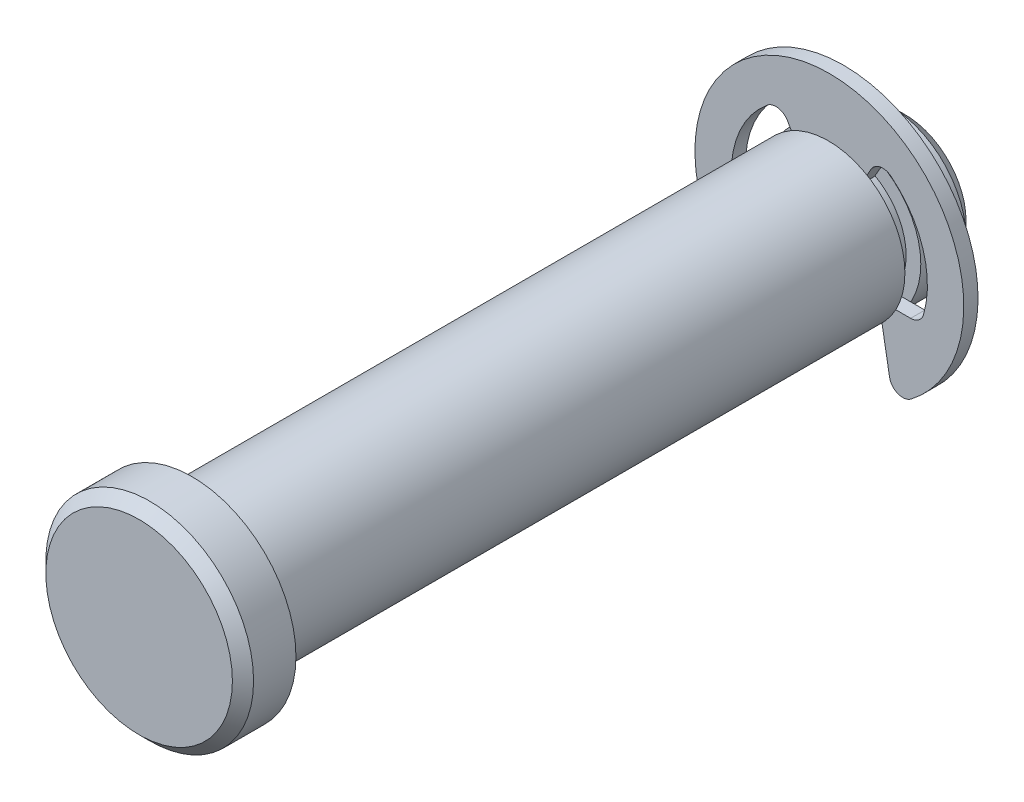
from build123d import *

# Parameters (mm, degrees)
SKETCH2_R      = 4.7625
EXTRUDE1_DEPTH = 22.225
SKETCH3_W      = 0.9906
SKETCH3_H      = 0.9144
SKETCH8_R      = 6.477
EXTRUDE6_DEPTH = 3.302
CHAMFER2_SIZE  = 0.6604
SKETCH4_R      = 8.382
SKETCH4_R_2    = 3.8481
EXTRUDE2_DEPTH = 0.4445
EXTRUDE4_DEPTH = 23.225
EXTRUDE5_DEPTH = 0.889
FILLET1_R      = 0.8382
CHAMFER1_SIZE  = 0.9525


with BuildPart() as part:
    # Sketch2 → Extrude1 (new body, symmetric)
    with BuildSketch(Plane.XY):
        Circle(SKETCH2_R)
    extrude(amount=EXTRUDE1_DEPTH, both=True)

    # Sketch3 → Cut-Revolve1 (revolve, cut)
    with BuildSketch(Plane(origin=(0, 0, 0), x_dir=(0, 0, -1), z_dir=(1, 0, 0))):
        with Locations((17.9578, 4.3053)):
            Rectangle(SKETCH3_W, SKETCH3_H)
    revolve(axis=Axis((0, 0, 22.225), (0, 0, -1)), mode=Mode.SUBTRACT)

    # Sketch8 → Extrude6 (add)
    with BuildSketch(Plane.XY.offset(22.225)):
        Circle(SKETCH8_R)
    extrude(amount=EXTRUDE6_DEPTH)

    # Chamfer2
    chamfer2_edges = [part.edges().sort_by_distance(p)[0] for p in [
        (-6.477, 0, 25.527),
    ]]
    chamfer(chamfer2_edges, length=CHAMFER2_SIZE)

    # Chamfer1
    chamfer1_edges = [part.edges().sort_by_distance(p)[0] for p in [
        (-4.7625, 0, -22.225),
    ]]
    chamfer(chamfer1_edges, length=CHAMFER1_SIZE)


with BuildPart() as body_2:
    # Sketch4 → Extrude2 (new body, symmetric)
    with BuildSketch(Plane.XY.offset(-17.9578)):
        Circle(SKETCH4_R)
        Circle(SKETCH4_R_2, mode=Mode.SUBTRACT)
    extrude(amount=EXTRUDE2_DEPTH, both=True)

    # Sketch5 → Extrude4 (cut, through all)
    with BuildSketch(Plane.XY):
        with BuildLine():
            Line((-3.057525, 5.295788645), (0, 0))
            Line((0, 0), (3.057525, 5.295788645))
            ThreePointArc((3.057525, 5.295788645), (5.785069674, 1.981616859), (5.662420154, -2.30886))
            Line((5.662420154, -2.30886), (3.07848, -2.30886))
            Line((3.07848, -2.30886), (3.972784338, -7.380711931))
            ThreePointArc((3.972784338, -7.380711931), (0, -8.382), (-3.972784338, -7.380711931))
            Line((-3.972784338, -7.380711931), (-3.07848, -2.30886))
            Line((-3.07848, -2.30886), (-5.662420154, -2.30886))
            ThreePointArc((-5.662420154, -2.30886), (-5.785069674, 1.981616859), (-3.057525, 5.295788645))
        make_face()
    extrude(amount=-EXTRUDE4_DEPTH, mode=Mode.SUBTRACT)

    # Sketch6 → Extrude5 (add)
    with BuildSketch(Plane.XY.offset(-17.5133)):
        with BuildLine():
            Line((-1.92405, 3.332552356), (1.92405, 3.332552356))
            ThreePointArc((1.92405, 3.332552356), (0, 3.8481), (-1.92405, 3.332552356))
        make_face()
    extrude(amount=-EXTRUDE5_DEPTH)

    # Fillet1
    fillet1_edges = [body_2.edges().sort_by_distance(p)[0] for p in [
        (3.057525, 5.295788645, -17.9578),
        (3.972784338, -7.380711931, -17.9578),
        (-5.662420154, -2.30886, -17.9578),
        (5.662420154, -2.30886, -17.9578),
        (-3.972784338, -7.380711931, -17.9578),
        (-3.057525, 5.295788645, -17.9578),
    ]]
    fillet(fillet1_edges, radius=FILLET1_R)


solid = Compound([part.part, body_2.part])
